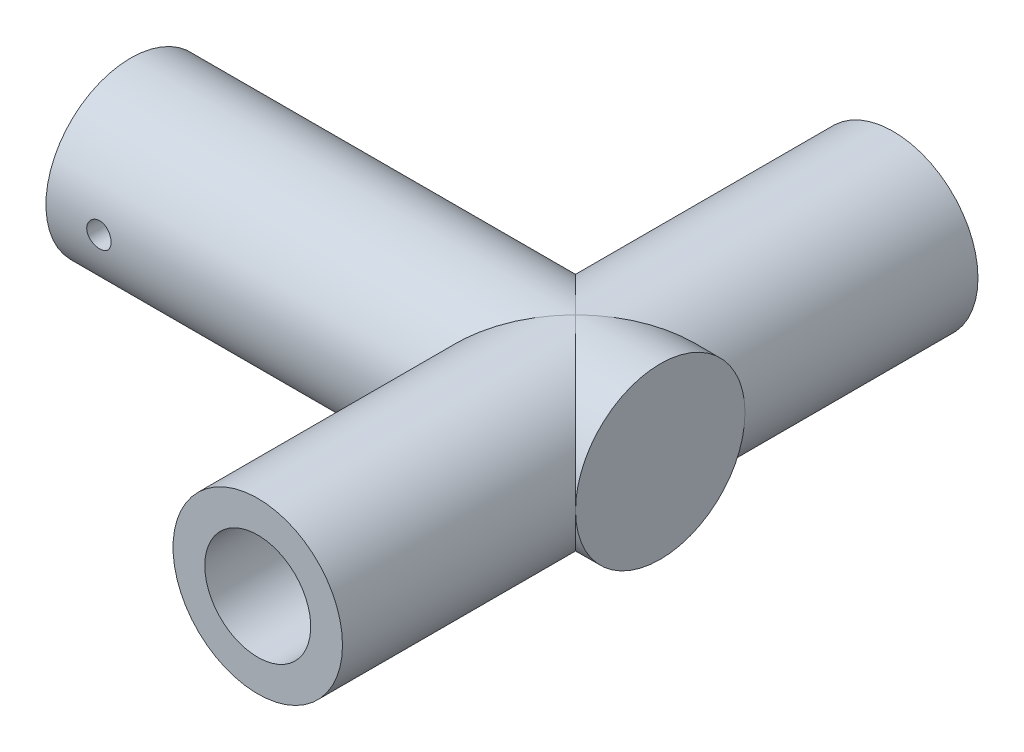
from build123d import *

# Parameters (mm, degrees)
SKETCH_2_R               = 8
EXTRUDE_1_DEPTH          = 50
SKETCH_3_R               = 4
CUT_EXTRUDE_1_DEPTH      = 40
CUT_EXTRUDE_2_DEPTH      = 52.264022472
CUT_EXTRUDE_2_DEPTH_BACK = 52.264022472
SKETCH_4_R               = 1.15
EXTRUDE_2_DEPTH          = 30
EXTRUDE_2_DEPTH_BACK     = 30
SKETCH_5_R               = 8
SKETCH_6_R               = 5
CUT_EXTRUDE_4_DEPTH      = 79.511145716


with BuildPart() as part:
    # 草图2 → 凸台-拉伸1 (new body)
    with BuildSketch(Plane(origin=(0, 0, 0), x_dir=(0, 0, -1), z_dir=(1, 0, 0))):
        Circle(SKETCH_2_R)
    extrude(amount=EXTRUDE_1_DEPTH)

    # 草图3 → 切除-拉伸1 (cut)
    with BuildSketch(Plane.ZY):
        Circle(SKETCH_3_R)
    extrude(amount=-CUT_EXTRUDE_1_DEPTH, mode=Mode.SUBTRACT)

    # 草图4 → 切除-拉伸2 (cut, two sides: drawn at the far end of the back side and taken through both)
    with BuildSketch(Plane.XY.offset(-CUT_EXTRUDE_2_DEPTH_BACK)):
        with Locations((5, 0)):
            Circle(SKETCH_4_R)
    extrude(amount=CUT_EXTRUDE_2_DEPTH + CUT_EXTRUDE_2_DEPTH_BACK, mode=Mode.SUBTRACT)

    # 草图5 → 凸台-拉伸2 (add, two sides: drawn at the far end of the back side and taken through both)
    with BuildSketch(Plane.XY.offset(-EXTRUDE_2_DEPTH_BACK)):
        with Locations((42, 0)):
            Circle(SKETCH_5_R)
    extrude(amount=EXTRUDE_2_DEPTH + EXTRUDE_2_DEPTH_BACK)

    # 草图6 → 切除-拉伸4 (cut, through all)
    with BuildSketch(Plane(origin=(0, 0, -30), x_dir=(-1, 0, 0), z_dir=(0, 0, -1))):
        with Locations((-42, 0)):
            Circle(SKETCH_6_R)
    extrude(amount=-CUT_EXTRUDE_4_DEPTH, mode=Mode.SUBTRACT)


solid = part.part
